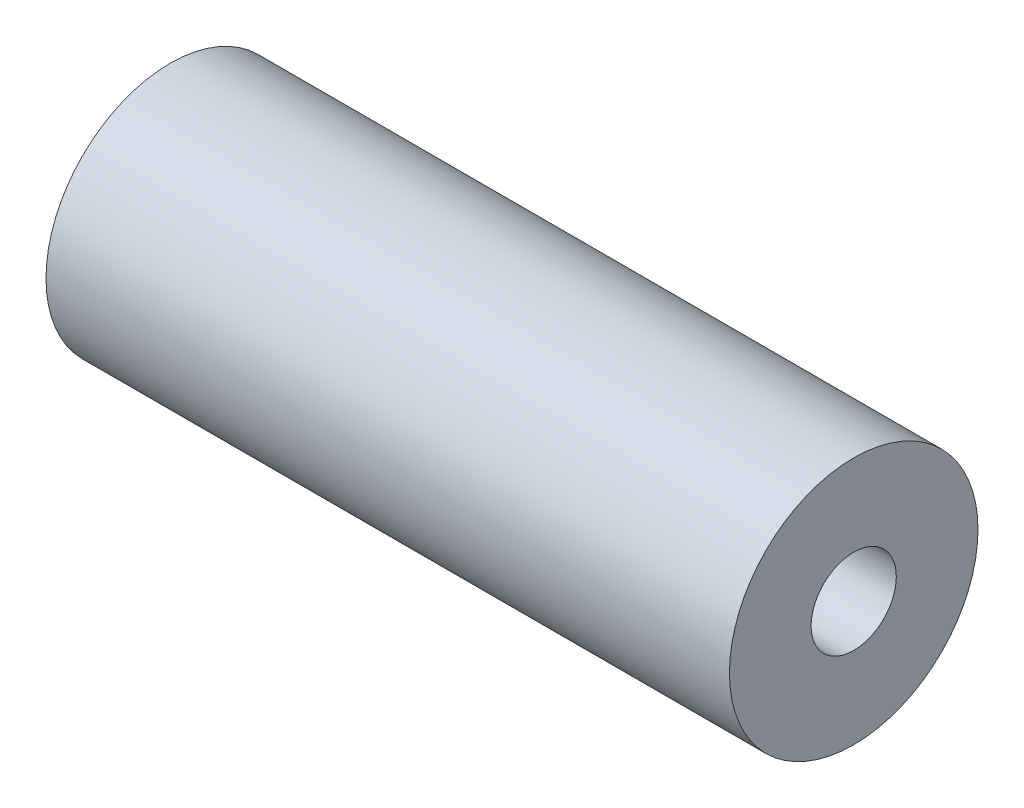
from build123d import *

# Parameters (mm, degrees)
SKETCH1_R           = 9.525
SKETCH1_R_2         = 3.2639
BOSS_EXTRUDE1_DEPTH = 52.3875


with BuildPart() as part:
    # Sketch1 → Boss-Extrude1 (new body)
    with BuildSketch(Plane(origin=(0, 0, 0), x_dir=(0, 0, -1), z_dir=(1, 0, 0))):
        Circle(SKETCH1_R)
        Circle(SKETCH1_R_2, mode=Mode.SUBTRACT)
    extrude(amount=BOSS_EXTRUDE1_DEPTH)


solid = part.part
